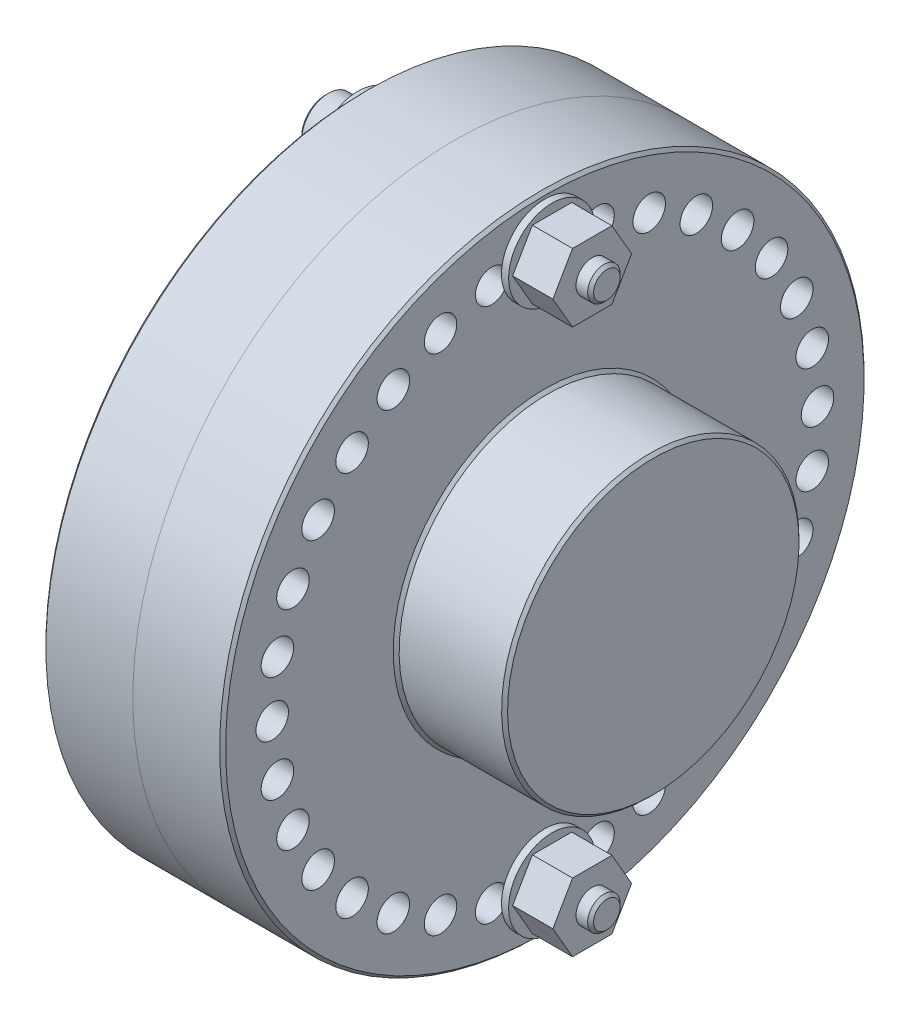
from build123d import *

# Parameters (mm, degrees)
CHAMFER2_SIZE       = 0.381
SKETCH2_R           = 2.0828
CUT_EXTRUDE1_DEPTH  = 37.909375
SKETCH3_R           = 2.0828
CUT_EXTRUDE2_DEPTH  = 37.909375
SKETCH4_R           = 5.55625
SKETCH4_R_2         = 2.38125
BOSS_EXTRUDE1_DEPTH = 0.9144
SKETCH5_R           = 3.429
BOSS_EXTRUDE2_DEPTH = 4.1656
CUT_EXTRUDE3_DEPTH  = 3.571875
SKETCH7_R           = 2.0828
BOSS_EXTRUDE4_DEPTH = 31.880175
SKETCH8_R           = 2.0828
BOSS_EXTRUDE5_DEPTH = 5.1562
CHAMFER1_SIZE       = 0.381


with BuildPart() as part:
    # Sketch1 → Revolve1 (revolve)
    with BuildSketch(Plane.XY):
        Polygon((0, 0), (0, 41.275), (-11.509375, 41.275), (-11.509375, 19.05), (-25.4, 19.05), (-25.4, 0), align=None)
    revolve(axis=Axis((0, 0, 0), (-1, 0, 0)))

    # Chamfer2
    chamfer2_edges = [part.edges().sort_by_distance(p)[0] for p in [
        (-25.4, -19.05, 0),
        (-11.509375, -19.05, 0),
        (-11.509375, -41.275, 0),
    ]]
    chamfer(chamfer2_edges, length=CHAMFER2_SIZE)


with BuildPart() as body_2:
    # Mirror1: mirrored copy
    add(part.part.mirror(Plane(origin=(0, 0, 0), x_dir=(0, 0, 1), z_dir=(1, 0, 0))))

    # Sketch3 → Cut-Extrude2 (cut, through all)
    with BuildSketch(Plane(origin=(11.509375, 0, 0), x_dir=(0, 0, -1), z_dir=(1, 0, 0))):
        with Locations(Location((0, 34.925, 0), (0, 0, 90))):  # turned: the seam where the file's is
            Circle(SKETCH3_R)
        with Locations(Location((6.813529496, 34.253925918, 0), (0, 0, 90))):  # turned: the seam where the file's is
            Circle(SKETCH3_R)
        with Locations(Location((13.365218875, 32.266492673, 0), (0, 0, 90))):  # turned: the seam where the file's is
            Circle(SKETCH3_R)
        with Locations(Location((19.403290388, 29.03907621, 0), (0, 0, 90))):  # turned: the seam where the file's is
            Circle(SKETCH3_R)
        with Locations(Location((24.695704333, 24.695704333, 0), (0, 0, 90))):  # turned: the seam where the file's is
            Circle(SKETCH3_R)
        with Locations(Location((29.03907621, 19.403290388, 0), (0, 0, 90))):  # turned: the seam where the file's is
            Circle(SKETCH3_R)
        with Locations(Location((32.266492673, 13.365218875, 0), (0, 0, 90))):  # turned: the seam where the file's is
            Circle(SKETCH3_R)
        with Locations(Location((34.253925918, 6.813529496, 0), (0, 0, 90))):  # turned: the seam where the file's is
            Circle(SKETCH3_R)
        with Locations(Location((34.925, 0, 0), (0, 0, 90))):  # turned: the seam where the file's is
            Circle(SKETCH3_R)
        with Locations(Location((34.253925918, -6.813529496, 0), (0, 0, 90))):  # turned: the seam where the file's is
            Circle(SKETCH3_R)
        with Locations(Location((32.266492673, -13.365218875, 0), (0, 0, 90))):  # turned: the seam where the file's is
            Circle(SKETCH3_R)
        with Locations(Location((29.03907621, -19.403290388, 0), (0, 0, 90))):  # turned: the seam where the file's is
            Circle(SKETCH3_R)
        with Locations(Location((24.695704333, -24.695704333, 0), (0, 0, 90))):  # turned: the seam where the file's is
            Circle(SKETCH3_R)
        with Locations(Location((19.403290388, -29.03907621, 0), (0, 0, 90))):  # turned: the seam where the file's is
            Circle(SKETCH3_R)
        with Locations(Location((13.365218875, -32.266492673, 0), (0, 0, 90))):  # turned: the seam where the file's is
            Circle(SKETCH3_R)
        with Locations(Location((6.813529496, -34.253925918, 0), (0, 0, 90))):  # turned: the seam where the file's is
            Circle(SKETCH3_R)
        with Locations(Location((0, -34.925, 0), (0, 0, 90))):  # turned: the seam where the file's is
            Circle(SKETCH3_R)
        with Locations(Location((-6.813529496, -34.253925918, 0), (0, 0, 90))):  # turned: the seam where the file's is
            Circle(SKETCH3_R)
        with Locations(Location((-13.365218875, -32.266492673, 0), (0, 0, 90))):  # turned: the seam where the file's is
            Circle(SKETCH3_R)
        with Locations(Location((-19.403290388, -29.03907621, 0), (0, 0, 90))):  # turned: the seam where the file's is
            Circle(SKETCH3_R)
        with Locations(Location((-24.695704333, -24.695704333, 0), (0, 0, 90))):  # turned: the seam where the file's is
            Circle(SKETCH3_R)
        with Locations(Location((-29.03907621, -19.403290388, 0), (0, 0, 90))):  # turned: the seam where the file's is
            Circle(SKETCH3_R)
        with Locations(Location((-32.266492673, -13.365218875, 0), (0, 0, 90))):  # turned: the seam where the file's is
            Circle(SKETCH3_R)
        with Locations(Location((-34.253925918, -6.813529496, 0), (0, 0, 90))):  # turned: the seam where the file's is
            Circle(SKETCH3_R)
        with Locations(Location((-34.925, 0, 0), (0, 0, 90))):  # turned: the seam where the file's is
            Circle(SKETCH3_R)
        with Locations(Location((-34.253925918, 6.813529496, 0), (0, 0, 90))):  # turned: the seam where the file's is
            Circle(SKETCH3_R)
        with Locations(Location((-32.266492673, 13.365218875, 0), (0, 0, 90))):  # turned: the seam where the file's is
            Circle(SKETCH3_R)
        with Locations(Location((-29.03907621, 19.403290388, 0), (0, 0, 90))):  # turned: the seam where the file's is
            Circle(SKETCH3_R)
        with Locations(Location((-24.695704333, 24.695704333, 0), (0, 0, 90))):  # turned: the seam where the file's is
            Circle(SKETCH3_R)
        with Locations(Location((-19.403290388, 29.03907621, 0), (0, 0, 90))):  # turned: the seam where the file's is
            Circle(SKETCH3_R)
        with Locations(Location((-13.365218875, 32.266492673, 0), (0, 0, 90))):  # turned: the seam where the file's is
            Circle(SKETCH3_R)
        with Locations(Location((-6.813529496, 34.253925918, 0), (0, 0, 90))):  # turned: the seam where the file's is
            Circle(SKETCH3_R)
    extrude(amount=-CUT_EXTRUDE2_DEPTH, mode=Mode.SUBTRACT)


with BuildPart() as part_1:
    add(part.part)

    # Sketch2 → Cut-Extrude1 (cut, through all)
    with BuildSketch(Plane.ZY.offset(11.509375)):
        with Locations(Location((0, 34.925, 0), (0, 0, 270))):  # turned: the seam where the file's is
            Circle(SKETCH2_R)
        with Locations(Location((6.41745191, 34.330335506, 0), (0, 0, 270))):  # turned: the seam where the file's is
            Circle(SKETCH2_R)
        with Locations(Location((12.616365192, 32.566592612, 0), (0, 0, 270))):  # turned: the seam where the file's is
            Circle(SKETCH2_R)
        with Locations(Location((18.385643288, 29.693833465, 0), (0, 0, 270))):  # turned: the seam where the file's is
            Circle(SKETCH2_R)
        with Locations(Location((23.528820354, 25.809886434, 0), (0, 0, 270))):  # turned: the seam where the file's is
            Circle(SKETCH2_R)
        with Locations(Location((27.870751663, 21.047014676, 0), (0, 0, 270))):  # turned: the seam where the file's is
            Circle(SKETCH2_R)
        with Locations(Location((31.263577951, 15.567412075, 0), (0, 0, 270))):  # turned: the seam where the file's is
            Circle(SKETCH2_R)
        with Locations(Location((33.591760588, 9.557679928, 0), (0, 0, 270))):  # turned: the seam where the file's is
            Circle(SKETCH2_R)
        with Locations(Location((34.776016107, 3.222472454, 0), (0, 0, 270))):  # turned: the seam where the file's is
            Circle(SKETCH2_R)
        with Locations(Location((34.776016107, -3.222472454, 0), (0, 0, 270))):  # turned: the seam where the file's is
            Circle(SKETCH2_R)
        with Locations(Location((33.591760588, -9.557679928, 0), (0, 0, 270))):  # turned: the seam where the file's is
            Circle(SKETCH2_R)
        with Locations(Location((31.263577951, -15.567412075, 0), (0, 0, 270))):  # turned: the seam where the file's is
            Circle(SKETCH2_R)
        with Locations(Location((27.870751663, -21.047014676, 0), (0, 0, 270))):  # turned: the seam where the file's is
            Circle(SKETCH2_R)
        with Locations(Location((23.528820354, -25.809886434, 0), (0, 0, 270))):  # turned: the seam where the file's is
            Circle(SKETCH2_R)
        with Locations(Location((18.385643288, -29.693833465, 0), (0, 0, 270))):  # turned: the seam where the file's is
            Circle(SKETCH2_R)
        with Locations(Location((12.616365192, -32.566592612, 0), (0, 0, 270))):  # turned: the seam where the file's is
            Circle(SKETCH2_R)
        with Locations(Location((6.41745191, -34.330335506, 0), (0, 0, 270))):  # turned: the seam where the file's is
            Circle(SKETCH2_R)
        with Locations(Location((0, -34.925, 0), (0, 0, 270))):  # turned: the seam where the file's is
            Circle(SKETCH2_R)
        with Locations(Location((-6.41745191, -34.330335506, 0), (0, 0, 270))):  # turned: the seam where the file's is
            Circle(SKETCH2_R)
        with Locations(Location((-12.616365192, -32.566592612, 0), (0, 0, 270))):  # turned: the seam where the file's is
            Circle(SKETCH2_R)
        with Locations(Location((-18.385643288, -29.693833465, 0), (0, 0, 270))):  # turned: the seam where the file's is
            Circle(SKETCH2_R)
        with Locations(Location((-23.528820354, -25.809886434, 0), (0, 0, 270))):  # turned: the seam where the file's is
            Circle(SKETCH2_R)
        with Locations(Location((-27.870751663, -21.047014676, 0), (0, 0, 270))):  # turned: the seam where the file's is
            Circle(SKETCH2_R)
        with Locations(Location((-31.263577951, -15.567412075, 0), (0, 0, 270))):  # turned: the seam where the file's is
            Circle(SKETCH2_R)
        with Locations(Location((-33.591760588, -9.557679928, 0), (0, 0, 270))):  # turned: the seam where the file's is
            Circle(SKETCH2_R)
        with Locations(Location((-34.776016107, -3.222472454, 0), (0, 0, 270))):  # turned: the seam where the file's is
            Circle(SKETCH2_R)
        with Locations(Location((-34.776016107, 3.222472454, 0), (0, 0, 270))):  # turned: the seam where the file's is
            Circle(SKETCH2_R)
        with Locations(Location((-33.591760588, 9.557679928, 0), (0, 0, 270))):  # turned: the seam where the file's is
            Circle(SKETCH2_R)
        with Locations(Location((-31.263577951, 15.567412075, 0), (0, 0, 270))):  # turned: the seam where the file's is
            Circle(SKETCH2_R)
        with Locations(Location((-27.870751663, 21.047014676, 0), (0, 0, 270))):  # turned: the seam where the file's is
            Circle(SKETCH2_R)
        with Locations(Location((-23.528820354, 25.809886434, 0), (0, 0, 270))):  # turned: the seam where the file's is
            Circle(SKETCH2_R)
        with Locations(Location((-18.385643288, 29.693833465, 0), (0, 0, 270))):  # turned: the seam where the file's is
            Circle(SKETCH2_R)
        with Locations(Location((-12.616365192, 32.566592612, 0), (0, 0, 270))):  # turned: the seam where the file's is
            Circle(SKETCH2_R)
        with Locations(Location((-6.41745191, 34.330335506, 0), (0, 0, 270))):  # turned: the seam where the file's is
            Circle(SKETCH2_R)
    extrude(amount=-CUT_EXTRUDE1_DEPTH, mode=Mode.SUBTRACT)


with BuildPart() as body_3:
    # Sketch4 → Boss-Extrude1 (new body)
    with BuildSketch(Plane.ZY.offset(11.509375)):
        with Locations(Location((0, 34.925, 0), (0, 0, 270))):  # turned: the seam where the file's is
            Circle(SKETCH4_R)
        with Locations(Location((0, 34.925, 0), (0, 0, 270))):  # turned: the seam where the file's is
            Circle(SKETCH4_R_2, mode=Mode.SUBTRACT)
    extrude(amount=BOSS_EXTRUDE1_DEPTH)


with BuildPart() as body_4:
    # Mirror2: mirrored copy
    add(body_3.part.mirror(Plane(origin=(0, 0, 0), x_dir=(0, 0, 1), z_dir=(1, 0, 0))))


with BuildPart() as body_5:
    # Sketch5 → Boss-Extrude2 (new body)
    with BuildSketch(Plane.ZY.offset(12.423775)):
        with Locations(Location((0, 34.925, 0), (0, 0, 270))):  # turned: the seam where the file's is
            Circle(SKETCH5_R)
    extrude(amount=BOSS_EXTRUDE2_DEPTH)

    # Sketch6 → Cut-Extrude3 (cut)
    with BuildSketch(Plane.ZY.offset(16.589375)):
        Polygon((0, 32.862777007), (1.7859375, 33.893888504), (1.7859375, 35.956111496), (0, 36.987222993), (-1.7859375, 35.956111496), (-1.7859375, 33.893888504), align=None)
    extrude(amount=-CUT_EXTRUDE3_DEPTH, mode=Mode.SUBTRACT)

    # Sketch7 → Boss-Extrude4 (add)
    with BuildSketch(Plane(origin=(-12.423775, 0, 0), x_dir=(0, 0, -1), z_dir=(1, 0, 0))):
        with Locations(Location((0, 34.925, 0), (0, 0, 270))):  # turned: the seam where the file's is
            Circle(SKETCH7_R)
    extrude(amount=BOSS_EXTRUDE4_DEPTH)

    # Chamfer1
    chamfer1_edges = [body_5.edges().sort_by_distance(p)[0] for p in [
        (19.4564, 37.0078, 0),
        (-16.589375, 38.354, 0),
    ]]
    chamfer(chamfer1_edges, length=CHAMFER1_SIZE)


with BuildPart() as body_6:
    # Sketch8 → Boss-Extrude5 (new body)
    with BuildSketch(Plane(origin=(12.423775, 0, 0), x_dir=(0, 0, -1), z_dir=(1, 0, 0))):
        Polygon((2.520494769, 39.290625), (-2.520494769, 39.290625), (-5.040989538, 34.925), (-2.520494769, 30.559375), (2.520494769, 30.559375), (5.040989538, 34.925), align=None)
        with Locations(Location((0, 34.925, 0), (0, 0, 90))):  # turned: the seam where the file's is
            Circle(SKETCH8_R, mode=Mode.SUBTRACT)
    extrude(amount=BOSS_EXTRUDE5_DEPTH)


with BuildPart() as body_7:
    # Mirror3: mirrored copy
    add(body_6.part.mirror(Plane.ZX))


with BuildPart() as body_8:
    # Mirror3 2: mirrored copy
    add(body_5.part.mirror(Plane.ZX))


with BuildPart() as body_9:
    # Mirror3 3: mirrored copy
    add(body_4.part.mirror(Plane.ZX))


with BuildPart() as body_10:
    # Mirror3 4: mirrored copy
    add(body_3.part.mirror(Plane.ZX))


solid = Compound([body_2.part, part_1.part, body_3.part, body_4.part, body_5.part, body_6.part, body_7.part, body_8.part, body_9.part, body_10.part])
